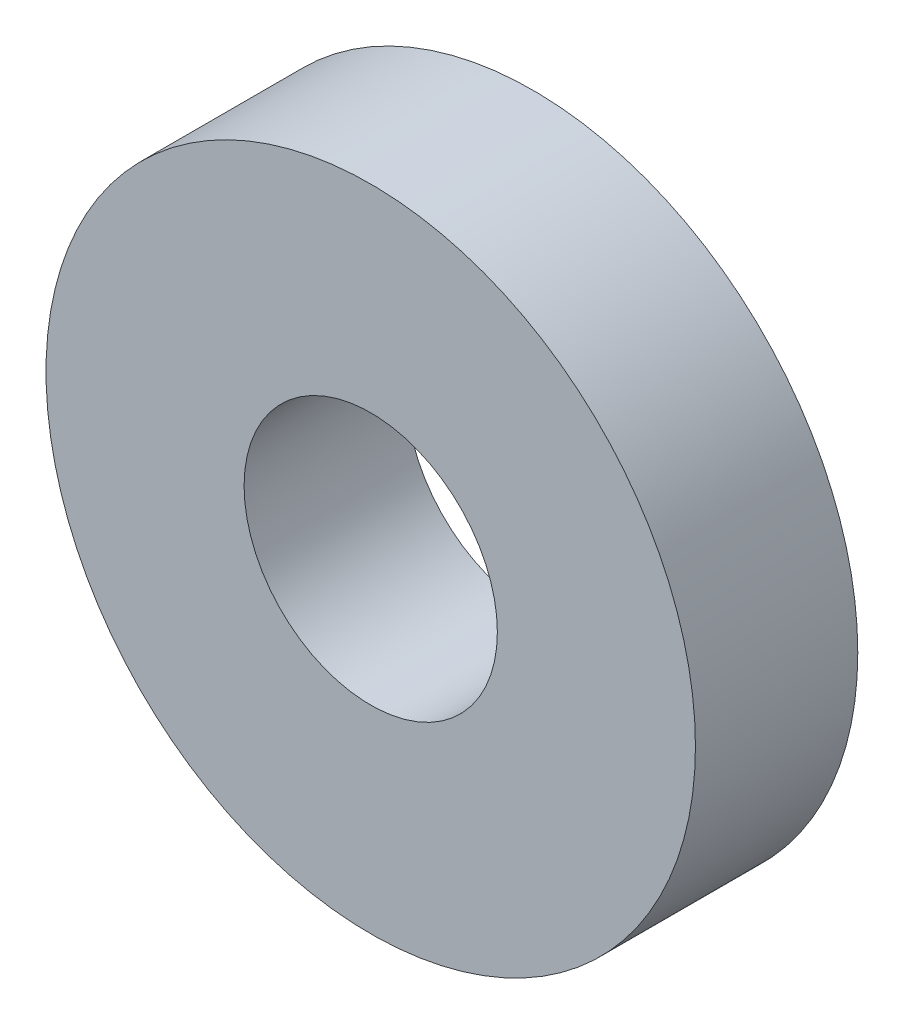
from build123d import *

# Parameters (mm, degrees)
SKETCH1_R           = 10
SKETCH1_R_2         = 3.9
BOSS_EXTRUDE1_DEPTH = 5


with BuildPart() as part:
    # Sketch1 → Boss-Extrude1 (new body)
    with BuildSketch(Plane.XY):
        Circle(SKETCH1_R)
        Circle(SKETCH1_R_2, mode=Mode.SUBTRACT)
    extrude(amount=BOSS_EXTRUDE1_DEPTH)


solid = part.part
